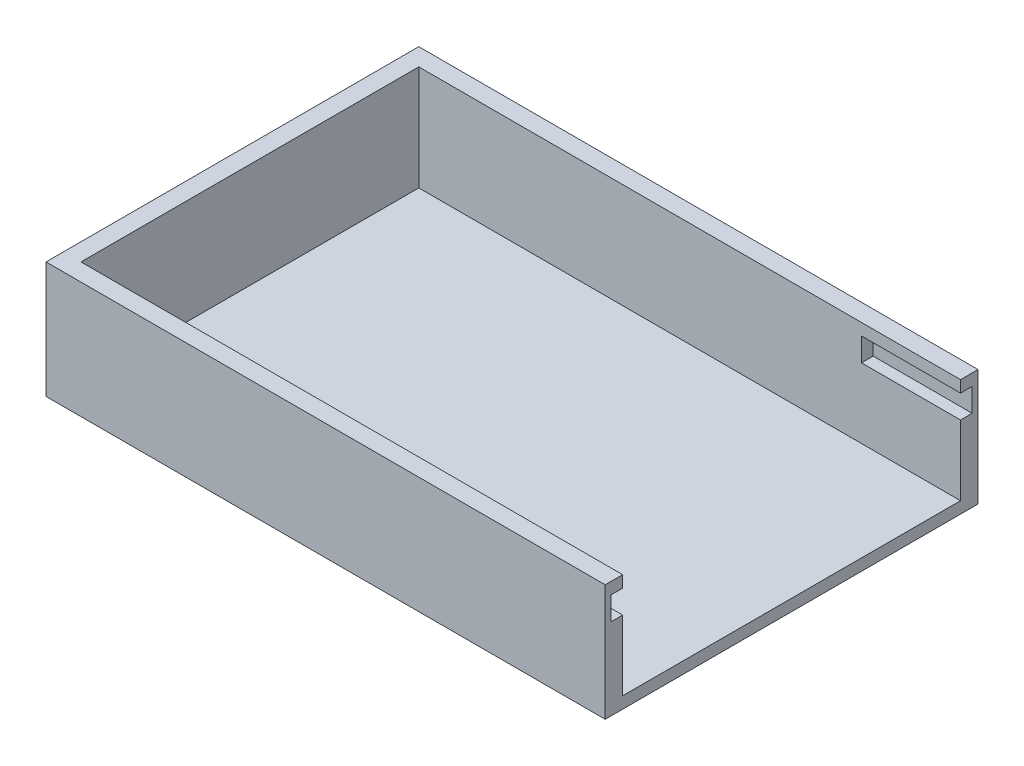
from build123d import *

# Parameters (mm, degrees)
SKETCH1_W           = 152.4
SKETCH1_H           = 101.6
BOSS_EXTRUDE1_DEPTH = 31.75
CUT_EXTRUDE1_DEPTH  = 28.575
SKETCH3_W           = 4.7625
SKETCH3_H           = 6.35
CUT_EXTRUDE2_DEPTH  = 26.9875


with BuildPart() as part:
    # Sketch1 → Boss-Extrude1 (new body)
    with BuildSketch(Plane(origin=(0, 0, 0), x_dir=(1, 0, 0), z_dir=(0, 1, 0))):
        Rectangle(SKETCH1_W, SKETCH1_H)
    extrude(amount=BOSS_EXTRUDE1_DEPTH)

    # Sketch2 → Cut-Extrude1 (cut)
    with BuildSketch(Plane(origin=(0, 31.75, 0), x_dir=(1, 0, 0), z_dir=(0, 1, 0))):
        Polygon((71.4375, -46.0375), (-71.4375, -46.0375), (-71.4375, 46.0375), (71.4375, 46.0375), (80.9625, 46.0375), (80.9625, -46.0375), align=None)
    extrude(amount=-CUT_EXTRUDE1_DEPTH, mode=Mode.SUBTRACT)

    # Sketch3 → Cut-Extrude2 (cut)
    with BuildSketch(Plane(origin=(76.2, 0, 0), x_dir=(0, 0, -1), z_dir=(1, 0, 0))):
        with Locations((-46.83125, 25.4)):
            Rectangle(SKETCH3_W, SKETCH3_H)
        with Locations((46.83125, 25.4)):
            Rectangle(SKETCH3_W, SKETCH3_H)
    extrude(amount=-CUT_EXTRUDE2_DEPTH, mode=Mode.SUBTRACT)


solid = part.part
